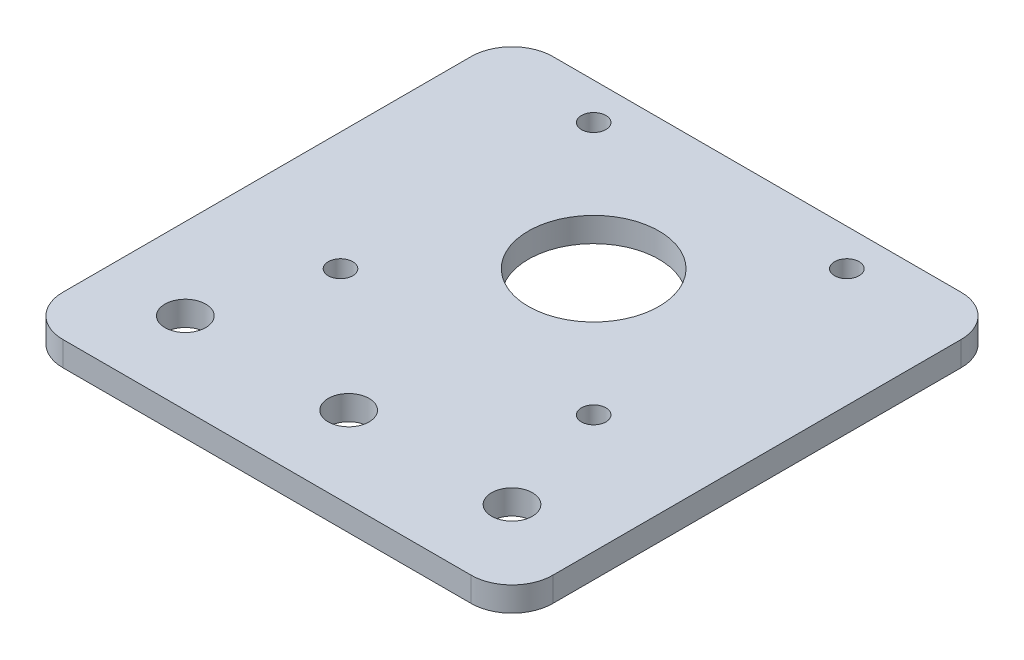
from build123d import *

# Parameters (mm, degrees)
SKETCH1_W            = 60
SKETCH1_H            = 60
SKETCH1_R            = 8
BOSS_EXTRUDE1_DEPTH  = 3
SKETCH2_R            = 1.5
CUT_EXTRUDE1_DEPTH   = 4
LPATTERN1_COUNT      = 2
LPATTERN1_PITCH      = 31
LPATTERN1_COUNT_DIR2 = 2
LPATTERN1_PITCH_DIR2 = 31
SKETCH3_R            = 2.5
CUT_EXTRUDE2_DEPTH   = 4
LPATTERN2_COUNT      = 3
LPATTERN2_PITCH      = 20
FILLET1_R            = 5


with BuildPart() as part:
    # Sketch1 → Boss-Extrude1 (new body)
    with BuildSketch(Plane(origin=(0, 0, 0), x_dir=(1, 0, 0), z_dir=(0, 1, 0))):
        with Locations((0, -10)):
            Rectangle(SKETCH1_W, SKETCH1_H)
        Circle(SKETCH1_R, mode=Mode.SUBTRACT)
    extrude(amount=BOSS_EXTRUDE1_DEPTH)

    # Sketch2 → Cut-Extrude1 (cut, through all)
    with BuildSketch(Plane(origin=(0, 3, 0), x_dir=(1, 0, 0), z_dir=(0, 1, 0))):
        with Locations((-15.5, 15.5)):
            Circle(SKETCH2_R)
    cut_extrude1 = extrude(amount=-CUT_EXTRUDE1_DEPTH, mode=Mode.SUBTRACT)

    # LPattern1: Cut-Extrude1 2 × 2
    with Locations(*[(i * LPATTERN1_PITCH, 0, j * LPATTERN1_PITCH_DIR2) for i in range(LPATTERN1_COUNT) for j in range(LPATTERN1_COUNT_DIR2) if (i, j) != (0, 0)]):
        add(cut_extrude1, mode=Mode.SUBTRACT)

    # Sketch3 → Cut-Extrude2 (cut, through all)
    with BuildSketch(Plane(origin=(0, 3, 0), x_dir=(1, 0, 0), z_dir=(0, 1, 0))):
        with Locations((-20, -30)):
            Circle(SKETCH3_R)
    cut_extrude2 = extrude(amount=-CUT_EXTRUDE2_DEPTH, mode=Mode.SUBTRACT)

    # LPattern2: Cut-Extrude2 ×3
    with Locations(*[(i * LPATTERN2_PITCH, 0, 0) for i in range(1, LPATTERN2_COUNT)]):
        add(cut_extrude2, mode=Mode.SUBTRACT)

    # Fillet1
    fillet1_edges = [part.edges().sort_by_distance(p)[0] for p in [
        (-30, 1.5, 40),
        (-30, 1.5, -20),
        (30, 1.5, -20),
        (30, 1.5, 40),
    ]]
    fillet(fillet1_edges, radius=FILLET1_R)


solid = part.part
